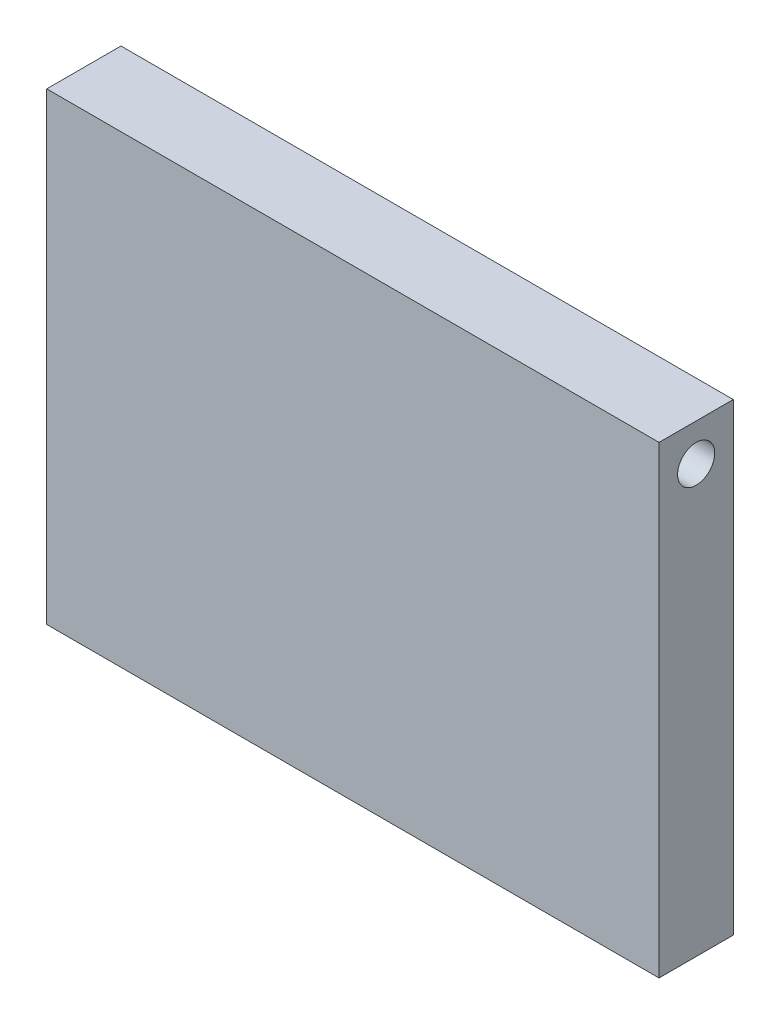
from build123d import *

# Parameters (mm, degrees)
CROQUIS1_W              = 33
CROQUIS1_H              = 4
SALIENTE_EXTRUIR1_DEPTH = 25
CROQUIS2_R              = 1
CORTAR_EXTRUIR1_DEPTH   = 34


with BuildPart() as part:
    # Croquis1 → Saliente-Extruir1 (new body)
    with BuildSketch(Plane(origin=(0, 0, 0), x_dir=(1, 0, 0), z_dir=(0, 1, 0))):
        with Locations((0.286127168, 0.813583815)):
            Rectangle(CROQUIS1_W, CROQUIS1_H)
    extrude(amount=SALIENTE_EXTRUIR1_DEPTH)

    # Croquis2 → Cortar-Extruir1 (cut, through all)
    with BuildSketch(Plane(origin=(16.786127168, 0, 0), x_dir=(0, 0, -1), z_dir=(1, 0, 0))):
        with Locations((0.813583815, 23)):
            Circle(CROQUIS2_R)
    extrude(amount=-CORTAR_EXTRUIR1_DEPTH, mode=Mode.SUBTRACT)


solid = part.part
